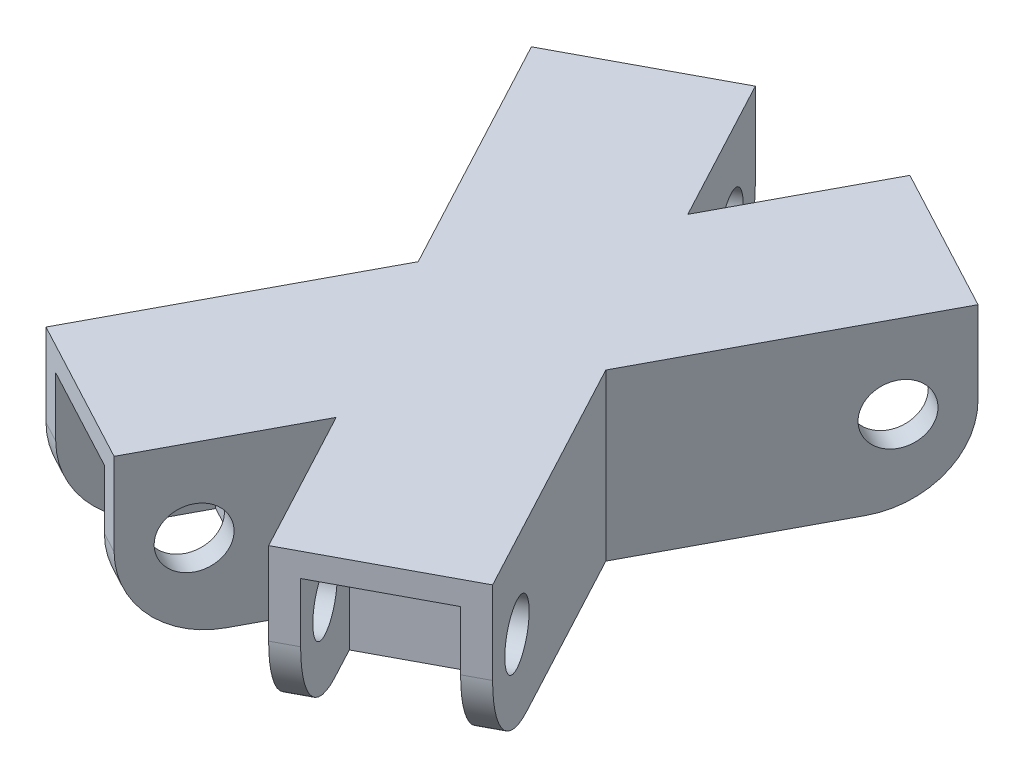
from build123d import *

# Parameters (mm, degrees)
BOSS_EXTRUDE1_DEPTH       = 35.56
CORTAR_EXTRUIR1_DEPTH     = 12.7
CORTAR_EXTRUIR2_DEPTH     = 12.7
CROQUIS4_R                = 6.35
CORTAR_EXTRUIR3_DEPTH     = 35.56
SIMETR_A7_COPY_1_SKETCH_R = 6.35
SIMETR_A7_COPY_1_DEPTH    = 35.56
REDONDEO1_R               = 17.78


with BuildPart() as part:
    # Sketch1 → Boss-Extrude1 (new body)
    with BuildSketch(Plane(origin=(0, 0, 0), x_dir=(1, 0, 0), z_dir=(0, 1, 0))):
        Polygon((47.97173767, 52.13499004), (20.15284418, 0), (47.971737664, -52.13499003), (16.598657301, -68.875462799), (0, -37.768156774), (-16.598657301, -68.875462799), (-32.285197483, -60.505226415), (-47.971737664, -52.13499003), (-20.15284418, 0), (-47.971737664, 52.13499003), (-32.285197483, 60.505226415), (-16.598657301, 68.875462799), (0, 37.768156774), (16.598657296, 68.875462789), (32.28519748, 60.505226416), align=None)
    extrude(amount=BOSS_EXTRUDE1_DEPTH)

    # Croquis2 → Cortar-Extruir1 (cut, symmetric)
    with BuildSketch(Plane(origin=(0, 0, 0), x_dir=(-0.470766951, 0, 0.882257603), z_dir=(-0.882257603, 0, -0.470766951))):
        with BuildLine():
            Line((55.88, 30.48), (68.58, 30.48))
            Line((68.58, 30.48), (68.58, 0))
            Line((68.58, 0), (43.18, 0))
            Line((43.18, 0), (43.18, 17.78))
            ThreePointArc((43.18, 17.78), (46.899743879, 26.760256121), (55.88, 30.48))
        make_face()
    cortar_extruir1 = extrude(amount=CORTAR_EXTRUIR1_DEPTH, both=True, mode=Mode.SUBTRACT)

    # Croquis3 → Cortar-Extruir2 (cut, symmetric)
    with BuildSketch(Plane(origin=(0, 0, 0), x_dir=(-0.470766951, 0, -0.882257603), z_dir=(0.882257603, 0, -0.470766951))):
        with BuildLine():
            Line((-55.88, 30.48), (-68.58, 30.48))
            Line((-68.58, 30.48), (-68.58, 0))
            Line((-68.58, 0), (-43.18, 0))
            Line((-43.18, 0), (-43.18, 17.78))
            ThreePointArc((-43.18, 17.78), (-46.899743879, 26.760256121), (-55.88, 30.48))
        make_face()
    cortar_extruir2 = extrude(amount=CORTAR_EXTRUIR2_DEPTH, both=True, mode=Mode.SUBTRACT)

    # Simetría1: Cortar-Extruir1, Cortar-Extruir2 across plane
    add(cortar_extruir1.mirror(Plane.XY), mode=Mode.SUBTRACT)
    add(cortar_extruir2.mirror(Plane.XY), mode=Mode.SUBTRACT)

    # Croquis4 → Cortar-Extruir3 (cut)
    with BuildSketch(Plane(origin=(-15.686540182, 0, -8.370236384), x_dir=(-0.470766951, 0, 0.882257603), z_dir=(-0.882257603, 0, -0.470766951))):
        with Locations((55.88, 17.78)):
            Circle(CROQUIS4_R)
    cortar_extruir3 = extrude(amount=-CORTAR_EXTRUIR3_DEPTH, mode=Mode.SUBTRACT)

    # Simetría2: Cortar-Extruir3 across plane
    add(cortar_extruir3.mirror(Plane(origin=(0, 0, 0), x_dir=(0, 0, 1), z_dir=(1, 0, 0))), mode=Mode.SUBTRACT)

    # Simetría7: Cortar-Extruir3 across plane
    add(cortar_extruir3.mirror(Plane.XY), mode=Mode.SUBTRACT)

    # Simetría7 copy 1 sketch → Simetría7 copy 1 (cut)
    with BuildSketch(Plane(origin=(15.686540182, 0, 8.370236384), x_dir=(0.470766951, 0, -0.882257603), z_dir=(0.882257603, 0, 0.470766951))):
        with Locations((55.88, 17.78)):
            Circle(SIMETR_A7_COPY_1_SKETCH_R)
    extrude(amount=-SIMETR_A7_COPY_1_DEPTH, mode=Mode.SUBTRACT)

    # Redondeo1
    redondeo1_edges = [part.edges().sort_by_distance(p)[0] for p in [
        (18.839591613, 0, 67.679714744),
        (-45.730803353, 0, 53.330738085),
        (-18.839591613, 0, -67.679714744),
        (45.730803357, 0, -53.330738094),
        (-18.839591613, 0, 67.679714744),
        (45.730803353, 0, 53.330738085),
        (-45.730803353, 0, -53.330738085),
        (18.839591608, 0, -67.679714736),
    ]]
    fillet(redondeo1_edges, radius=REDONDEO1_R)


solid = part.part
